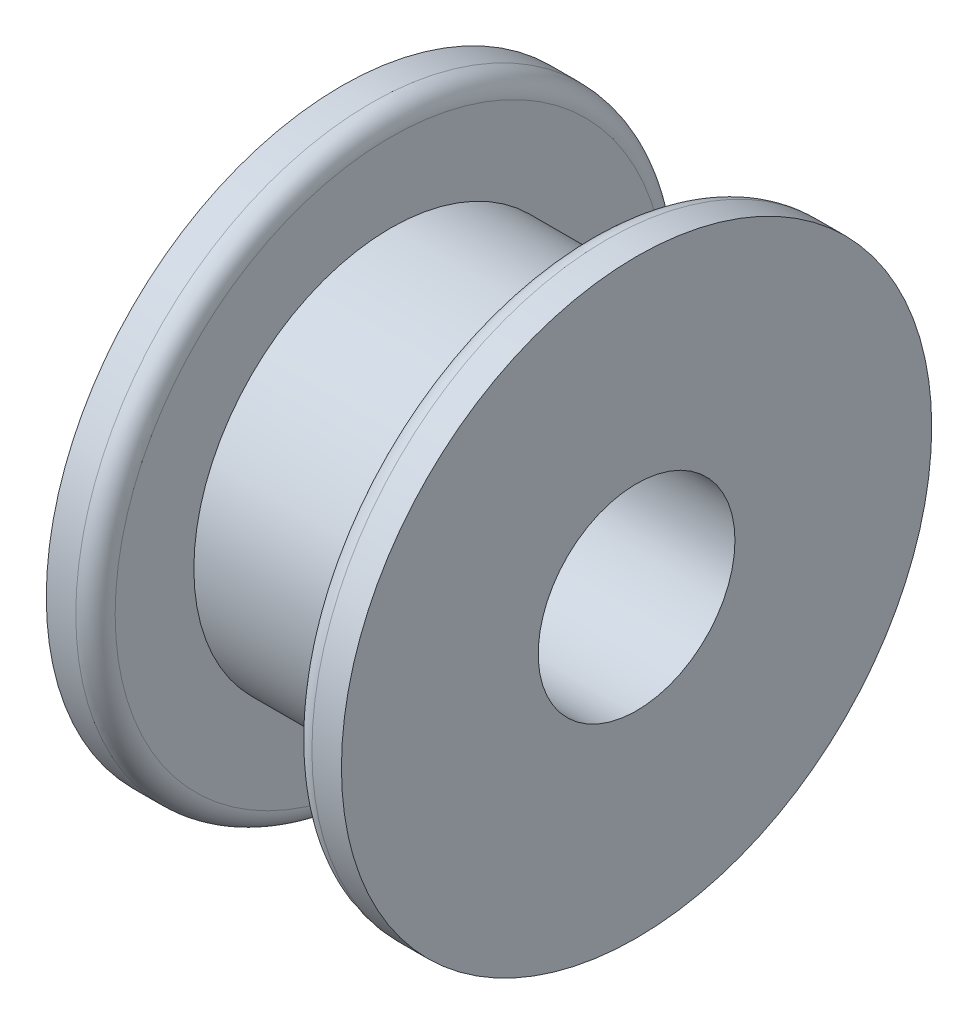
from build123d import *

# Parameters (mm, degrees)
SKETCH1_R            = 12.7
BOSS_EXTRUDE1_DEPTH  = 6.35
SKETCH2_R            = 19.05
BOSS_EXTRUDE2_DEPTH  = 3.175
FILLET1_R            = 1.27
FILLET1_OF_MIRROR1_R = 1.27
CUT_EXTRUDE1_REACH   = 21.05
SKETCH3_R            = 6.35


with BuildPart() as part:
    # Sketch1 → Boss-Extrude1 (new body)
    with BuildSketch(Plane(origin=(0, 0, 0), x_dir=(0, 0, -1), z_dir=(1, 0, 0))):
        Circle(SKETCH1_R)
    boss_extrude1 = extrude(amount=BOSS_EXTRUDE1_DEPTH)

    # Sketch2 → Boss-Extrude2 (add)
    with BuildSketch(Plane(origin=(6.35, 0, 0), x_dir=(0, 0, -1), z_dir=(1, 0, 0))):
        Circle(SKETCH2_R)
    boss_extrude2 = extrude(amount=BOSS_EXTRUDE2_DEPTH)

    # Fillet1
    fillet1_edges = [part.edges().sort_by_distance(p)[0] for p in [
        (6.35, 0, 19.05),
    ]]
    fillet(fillet1_edges, radius=FILLET1_R)

    # Mirror1: Boss-Extrude1, Boss-Extrude2 across plane
    add(boss_extrude1.mirror(Plane(origin=(0, 0, 0), x_dir=(0, 0, 1), z_dir=(1, 0, 0))))
    add(boss_extrude2.mirror(Plane(origin=(0, 0, 0), x_dir=(0, 0, 1), z_dir=(1, 0, 0))))

    # Fillet1 of Mirror1
    fillet1_of_mirror1_edges = [part.edges().sort_by_distance(p)[0] for p in [
        (-6.35, 0, 19.05),
    ]]
    fillet(fillet1_of_mirror1_edges, radius=FILLET1_OF_MIRROR1_R)

    # Sketch3 → Cut-Extrude1 (cut, up to next)
    with BuildSketch(Plane(origin=(9.525, 0, 0), x_dir=(0, 0, -1), z_dir=(1, 0, 0)), mode=Mode.PRIVATE) as cut_extrude1_sk1:
        Circle(SKETCH3_R)
    cut_extrude1_tool1 = extrude(cut_extrude1_sk1.sketch, amount=-CUT_EXTRUDE1_REACH, mode=Mode.PRIVATE) & part.part
    add(cut_extrude1_tool1.solids().sort_by_distance((9.525, 0, 0))[0], mode=Mode.SUBTRACT)


solid = part.part
